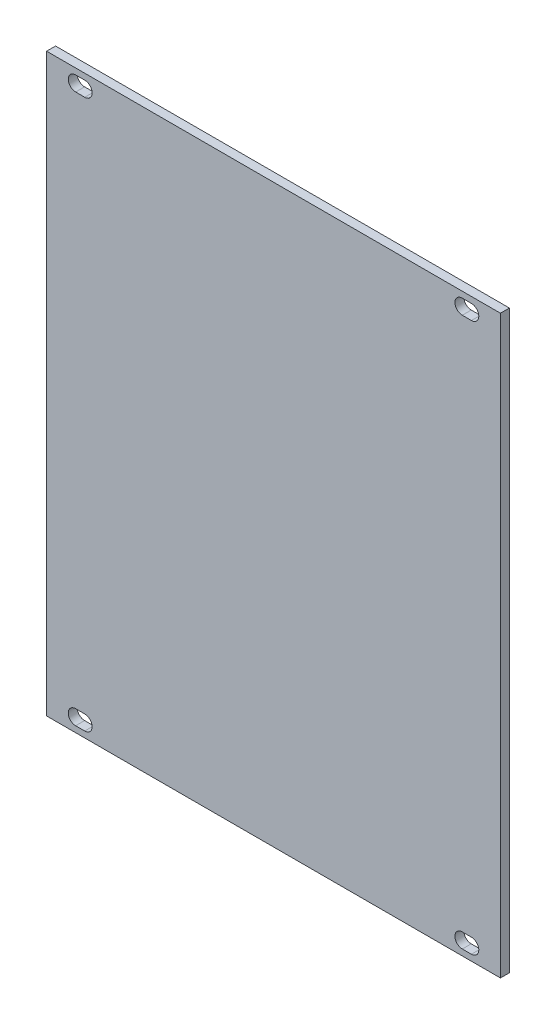
from build123d import *

# Parameters (mm, degrees)
SKETCH1_W           = 101.3
SKETCH1_H           = 128.5
BOSS_EXTRUDE1_DEPTH = 2


with BuildPart() as part:
    # Sketch1 → Boss-Extrude1 (new body)
    with BuildSketch(Plane.XY):
        Rectangle(SKETCH1_W, SKETCH1_H)
        with BuildLine():
            Line((-44.166, -59.6), (-42.134, -59.6))
            ThreePointArc((-42.134, -59.6), (-40.484, -61.25), (-42.134, -62.9))
            Line((-42.134, -62.9), (-44.166, -62.9))
            ThreePointArc((-44.166, -62.9), (-45.816, -61.25), (-44.166, -59.6))
        make_face(mode=Mode.SUBTRACT)
        with BuildLine():
            Line((-44.166, 62.9), (-42.134, 62.9))
            ThreePointArc((-42.134, 62.9), (-40.484, 61.25), (-42.134, 59.6))
            Line((-42.134, 59.6), (-44.166, 59.6))
            ThreePointArc((-44.166, 59.6), (-45.816, 61.25), (-44.166, 62.9))
        make_face(mode=Mode.SUBTRACT)
        with BuildLine():
            Line((42.134000014, 62.9), (44.166000014, 62.9))
            ThreePointArc((44.166000014, 62.9), (45.816000014, 61.25), (44.166000014, 59.6))
            Line((44.166000014, 59.6), (42.134000014, 59.6))
            ThreePointArc((42.134000014, 59.6), (40.484000014, 61.25), (42.134000014, 62.9))
        make_face(mode=Mode.SUBTRACT)
        with BuildLine():
            Line((42.134000014, -59.6), (44.166000014, -59.6))
            ThreePointArc((44.166000014, -59.6), (45.816000014, -61.25), (44.166000014, -62.9))
            Line((44.166000014, -62.9), (42.134000014, -62.9))
            ThreePointArc((42.134000014, -62.9), (40.484000014, -61.25), (42.134000014, -59.6))
        make_face(mode=Mode.SUBTRACT)
    extrude(amount=BOSS_EXTRUDE1_DEPTH)


solid = part.part
